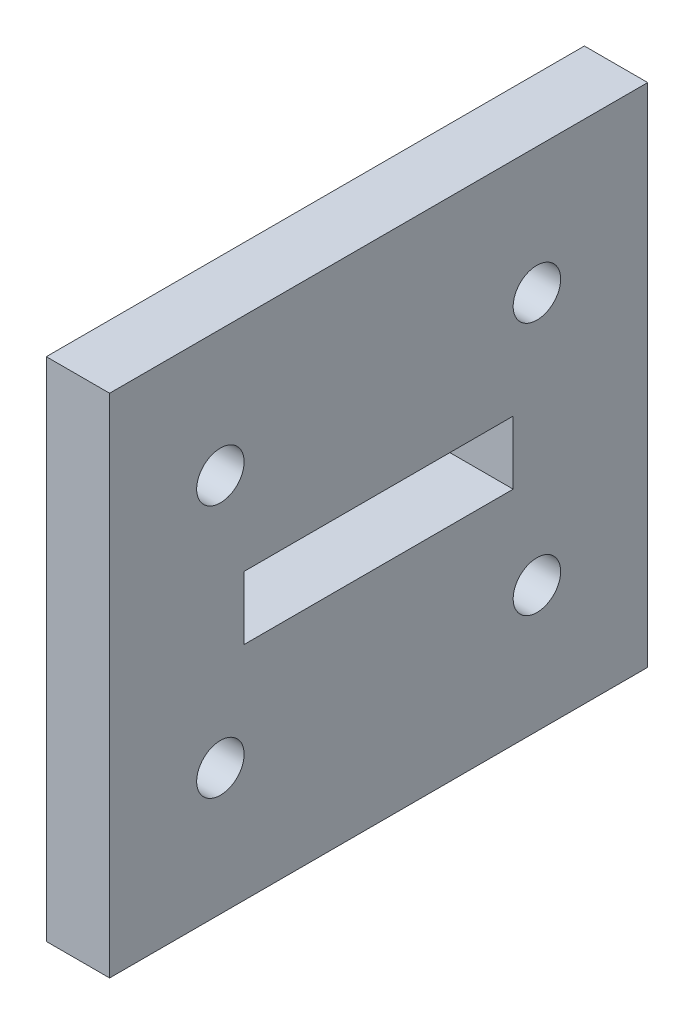
from build123d import *

# Parameters (mm, degrees)
SKETCH_1_W          = 34
SKETCH_1_H          = 32
SKETCH_1_R          = 1.5
EXTRUDE_1_DEPTH     = 4
SKETCH_2_W          = 17
SKETCH_2_H          = 4
CUT_EXTRUDE_1_DEPTH = 5


with BuildPart() as part:
    # Эскиз1 → Бобышка-Вытянуть1 (new body)
    with BuildSketch(Plane(origin=(25.2, 0, 0), x_dir=(0, 0, -1), z_dir=(1, 0, 0))):
        with Locations((3.763696673, 23.493617857)):
            Rectangle(SKETCH_1_W, SKETCH_1_H)
        with Locations((-6.236303327, 31.493617857)):
            Circle(SKETCH_1_R, mode=Mode.SUBTRACT)
        with Locations((13.763696673, 31.493617857)):
            Circle(SKETCH_1_R, mode=Mode.SUBTRACT)
        with Locations((-6.236303327, 15.493617857)):
            Circle(SKETCH_1_R, mode=Mode.SUBTRACT)
        with Locations((13.763696673, 15.493617857)):
            Circle(SKETCH_1_R, mode=Mode.SUBTRACT)
    extrude(amount=EXTRUDE_1_DEPTH)

    # Эскиз2 → Вырез-Вытянуть1 (cut, through all)
    with BuildSketch(Plane(origin=(29.2, 0, 0), x_dir=(0, 0, -1), z_dir=(1, 0, 0))):
        with Locations((3.763696673, 23.493617857)):
            Rectangle(SKETCH_2_W, SKETCH_2_H)
    extrude(amount=-CUT_EXTRUDE_1_DEPTH, mode=Mode.SUBTRACT)


solid = part.part
